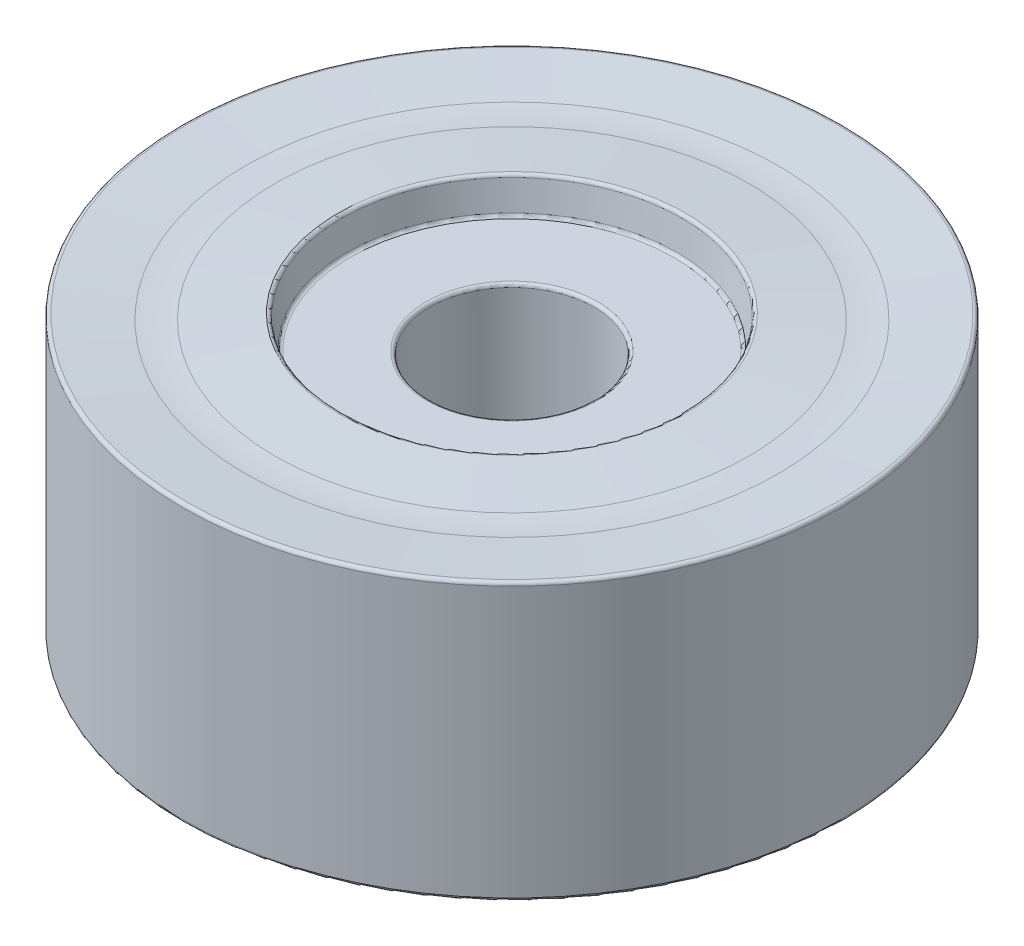
from build123d import *

# Parameters (mm, degrees)
ZAOKR_GLENIE1_R = 0.1


with BuildPart() as part:
    # Szkic1 → Obr_t1 (revolve)
    with BuildSketch(Plane(origin=(0, 0, 0), x_dir=(0, 0, -1), z_dir=(1, 0, 0))):
        with BuildLine():
            Line((2.5, 3.5), (6.5, 3.5))
            Line((6.5, 3.5), (6.5, 0))
            Line((6.5, 0), (10, 0))
            Line((10, 0), (10, 8.4))
            Line((10, 8.4), (8.088890415, 8.221635211))
            ThreePointArc((8.088890415, 8.221635211), (7.632643691, 8.200007033), (7.176326981, 8.220104568))
            Line((7.176326981, 8.220104568), (5.176326981, 8.4))
            Line((5.176326981, 8.4), (5, 7.4))
            Line((5, 7.4), (2.5, 7.4))
            Line((2.5, 7.4), (2.5, 3.5))
        make_face()
    revolve(axis=Axis((0, 8.4, 0), (0, -1, 0)))

    # Szkic1_2 → Obr_t2 (revolve)
    with BuildSketch(Plane(origin=(0, 0, 0), x_dir=(0, 0, -1), z_dir=(1, 0, 0))):
        with BuildLine():
            Line((2.5, 3.5), (6.5, 3.5))
            Line((6.5, 3.5), (6.5, 0))
            Line((6.5, 0), (10, 0))
            Line((10, 0), (10, 8.4))
            Line((10, 8.4), (8.088890415, 8.221635211))
            ThreePointArc((8.088890415, 8.221635211), (7.632643691, 8.200007033), (7.176326981, 8.220104568))
            Line((7.176326981, 8.220104568), (5.176326981, 8.4))
            Line((5.176326981, 8.4), (5, 7.4))
            Line((5, 7.4), (2.5, 7.4))
            Line((2.5, 7.4), (2.5, 3.5))
        make_face()
    revolve(axis=Axis((0, 8.4, 0), (0, -1, 0)))

    # Zaokr_glenie1
    zaokr_glenie1_edges = [part.edges().sort_by_distance(p)[0] for p in [
        (0, 0, 10),
        (0, 8.4, 10),
        (0, 8.4, 5.176326981),
        (0, 7.4, 5),
        (0, 7.4, 2.5),
        (0, 3.5, 2.5),
        (0, 3.5, 6.5),
        (0, 0, 6.5),
    ]]
    fillet(zaokr_glenie1_edges, radius=ZAOKR_GLENIE1_R)


solid = part.part
